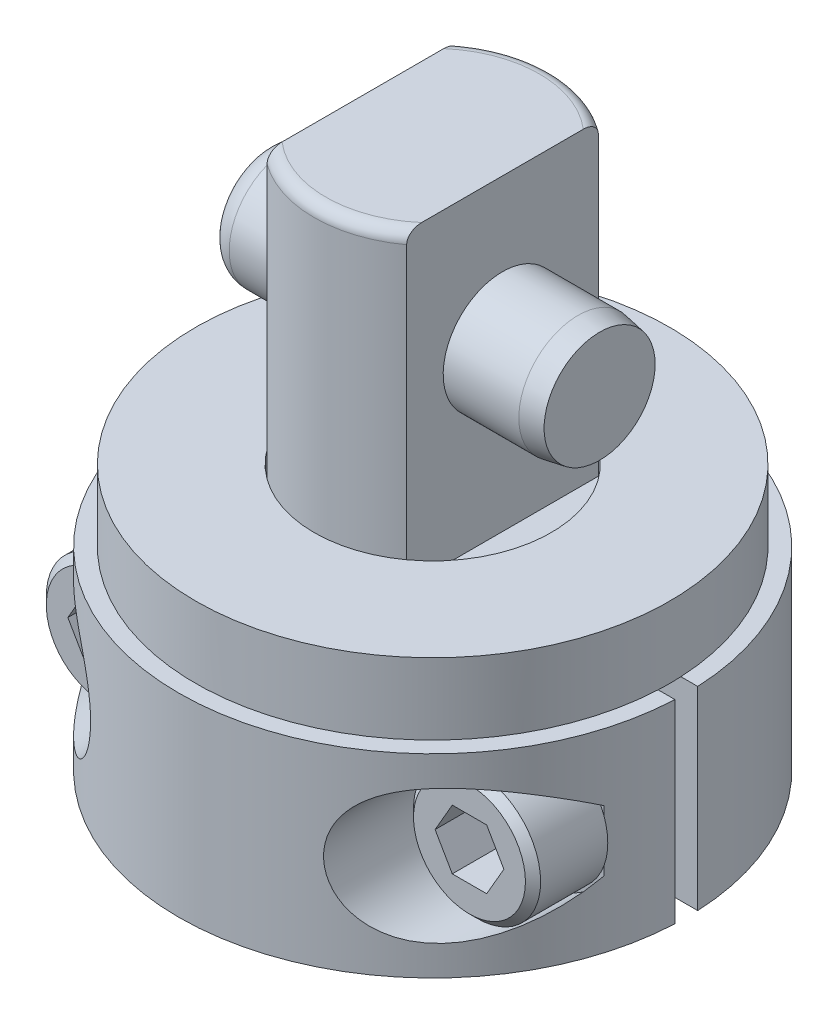
from build123d import *

# Parameters (mm, degrees)
FILLET1_R                  = 0.7874
SKETCH2_W                  = 3.2639
SKETCH2_H                  = 20.6248
CUT_EXTRUDE1_DEPTH         = 8.9375
CUT_EXTRUDE1_DEPTH_BACK    = 8.9375
SKETCH3_R                  = 5.0038
SKETCH3_R_2                = 3.9624
CUT_EXTRUDE2_DEPTH         = 2.54
CHAMFER1_SIZE              = 0.762
SKETCH4_R                  = 3.97129
EXTRUDE1_DEPTH             = 11.176
CHAMFER2_SIZE              = 0.254
CHAMFER2_SIZE2             = 1.440505582
FILLET2_R                  = 1.524
EXTRUDE2_DEPTH             = 6.5
EXTRUDE2_DEPTH_BACK        = 6.5
CUT_EXTRUDE3_START         = 4.064
SKETCH6_R                  = 4.4958
CUT_EXTRUDE3_DEPTH         = 13.174
SKETCH7_R                  = 4.2545
EXTRUDE3_DEPTH             = 5.0038
CHAMFER3_SIZE              = 0.508
CUT_EXTRUDE4_DEPTH         = 3.9878
EXTRUDE4_REACH             = 19
SKETCH10_R                 = 2.5019
EXTRUDE4_DIRECTION_2_REACH = 19
SKETCH11_R                 = 15.875
SKETCH11_R_2               = 7.9375
EXTRUDE5_DEPTH             = 4.774946


with BuildPart() as part:
    # Sketch1 → Revolve1 (revolve)
    with BuildSketch(Plane(origin=(0, 0, 0), x_dir=(0, 0, -1), z_dir=(1, 0, 0))):
        Polygon((0, 30.3276), (7.9375, 30.3276), (7.9375, 1.3462), (5.0038, 1.3462), (5.0038, -9.8298), (0, -9.8298), align=None)
    revolve(axis=Axis((0, -15.35938, 0), (0, 1, 0)))

    # Fillet1
    fillet1_edges = [part.edges().sort_by_distance(p)[0] for p in [
        (0, 30.3276, 7.9375),
    ]]
    fillet(fillet1_edges, radius=FILLET1_R)

    # Sketch2 → Cut-Extrude1 (cut, two sides)
    with BuildSketch(Plane.XY) as cut_extrude1_sk:
        with Locations((6.30555, 20.0152)):
            Rectangle(SKETCH2_W, SKETCH2_H)
        with Locations((-6.30555, 20.0152)):
            Rectangle(SKETCH2_W, SKETCH2_H)
    extrude(amount=CUT_EXTRUDE1_DEPTH, mode=Mode.SUBTRACT)
    extrude(cut_extrude1_sk.sketch, amount=-CUT_EXTRUDE1_DEPTH_BACK, mode=Mode.SUBTRACT)

    # Sketch3 → Cut-Extrude2 (cut)
    with BuildSketch(Plane.XZ.offset(-1.3462)):
        with Locations(Location((0, 0, 0), (0, 0, 270))):  # turned: the seam where the file's is
            Circle(SKETCH3_R)
        with Locations(Location((0, 0, 0), (0, 0, 270))):  # turned: the seam where the file's is
            Circle(SKETCH3_R_2, mode=Mode.SUBTRACT)
    extrude(amount=CUT_EXTRUDE2_DEPTH, mode=Mode.SUBTRACT)

    # Chamfer1
    chamfer1_edges = [part.edges().sort_by_distance(p)[0] for p in [
        (0, -9.8298, 5.0038),
    ]]
    chamfer(chamfer1_edges, length=CHAMFER1_SIZE)

    # Sketch4 → Extrude1 (add, symmetric)
    with BuildSketch(Plane(origin=(0, 0, 0), x_dir=(0, 0, -1), z_dir=(1, 0, 0))):
        with Locations(Location((0, 20.8026, 0), (0, 0, 90))):  # turned: the seam where the file's is
            Circle(SKETCH4_R)
    extrude(amount=EXTRUDE1_DEPTH, both=True)

    # Chamfer2
    chamfer2_edges = [part.edges().sort_by_distance(p)[0] for p in [
        (11.176, 16.83131, 0),
    ]]
    chamfer2_side = [part.faces().sort_by_distance(p)[0] for p in [
        (11.176, 20.8026, 0),
    ]]
    chamfer(chamfer2_edges, length=CHAMFER2_SIZE, length2=CHAMFER2_SIZE2, reference=chamfer2_side[0])

    # Fillet2
    fillet2_edges = [part.edges().sort_by_distance(p)[0] for p in [
        (-11.176, 16.83131, 0),
    ]]
    fillet(fillet2_edges, radius=FILLET2_R)

    # Sketch5 → Extrude2 (add, two sides)
    with BuildSketch(Plane(origin=(0, 0, 0), x_dir=(1, 0, 0), z_dir=(0, 1, 0))) as extrude2_sk:
        with BuildLine():
            Line((7.900839338, 0.762), (16.982913649, 0.762))
            ThreePointArc((16.982913649, 0.762), (0, 17), (-16.982913649, 0.762))
            Line((-16.982913649, 0.762), (-7.900839338, 0.762))
            ThreePointArc((-7.900839338, 0.762), (0, 7.9375), (7.900839338, 0.762))
        make_face()
        with BuildLine():
            Line((7.900839338, -0.762), (16.982913649, -0.762))
            ThreePointArc((16.982913649, -0.762), (0, -17), (-16.982913649, -0.762))
            Line((-16.982913649, -0.762), (-7.900839338, -0.762))
            ThreePointArc((-7.900839338, -0.762), (0, -7.9375), (7.900839338, -0.762))
        make_face()
    extrude(amount=EXTRUDE2_DEPTH)
    extrude(extrude2_sk.sketch, amount=-EXTRUDE2_DEPTH_BACK)

    # Sketch6 → Cut-Extrude3 (cut, through all)
    with BuildSketch(Plane.XY.offset(0.762).offset(CUT_EXTRUDE3_START)):
        with Locations((12.2936, 0)):
            Circle(SKETCH6_R)
        with Locations((-12.2936, 0)):
            Circle(SKETCH6_R)
    extrude(amount=CUT_EXTRUDE3_DEPTH, mode=Mode.SUBTRACT)

    # Sketch7 → Extrude3 (add)
    with BuildSketch(Plane.XY.offset(4.826)):
        with Locations(Location((12.2936, 0, 0), (0, 0, 340.36075817))):  # turned: the seam where the file's is
            Circle(SKETCH7_R)
        with Locations(Location((-12.2936, 0, 0), (0, 0, 160.36075817))):  # turned: the seam where the file's is
            Circle(SKETCH7_R)
    extrude(amount=EXTRUDE3_DEPTH)

    # Chamfer3
    chamfer3_edges = [part.edges().sort_by_distance(p)[0] for p in [
        (8.286594981, 1.429923433, 9.8298),
        (-8.286594981, -1.429923433, 9.8298),
    ]]
    chamfer(chamfer3_edges, length=CHAMFER3_SIZE)

    # Sketch8 → Cut-Extrude4 (cut)
    with BuildSketch(Plane.XY.offset(9.8298)):
        Polygon((13.444778702, 1.9939), (14.595957403, 0), (13.444778702, -1.9939), (11.142421298, -1.9939), (9.991242597, 0), (11.142421298, 1.9939), align=None)
        Polygon((-14.595957403, 0), (-13.444778702, -1.9939), (-11.142421298, -1.9939), (-9.991242597, 0), (-11.142421298, 1.9939), (-13.444778702, 1.9939), align=None)
    extrude(amount=-CUT_EXTRUDE4_DEPTH, mode=Mode.SUBTRACT)

    # Sketch10 → Extrude4 (add, up to next)
    with BuildSketch(Plane.XY, mode=Mode.PRIVATE) as extrude4_sk1:
        with Locations((12.2936, 0)):
            Circle(SKETCH10_R)
    extrude4_tool1 = extrude(extrude4_sk1.sketch, amount=EXTRUDE4_REACH, mode=Mode.PRIVATE) - part.part
    add(extrude4_tool1.solids().sort_by_distance((12.2936, 0, 0))[0])
    # Sketch10 → Extrude4 (add, up to next)
    with BuildSketch(Plane.XY, mode=Mode.PRIVATE) as extrude4_sk2:
        with Locations((-12.2936, 0)):
            Circle(SKETCH10_R)
    extrude4_tool2 = extrude(extrude4_sk2.sketch, amount=EXTRUDE4_REACH, mode=Mode.PRIVATE) - part.part
    add(extrude4_tool2.solids().sort_by_distance((-12.2936, 0, 0))[0])

    # Sketch10 → Extrude4 direction 2 (add, up to next)
    with BuildSketch(Plane.XY, mode=Mode.PRIVATE) as extrude4_direction_2_sk1:
        with Locations((12.2936, 0)):
            Circle(SKETCH10_R)
    extrude4_direction_2_tool1 = extrude(extrude4_direction_2_sk1.sketch, amount=-EXTRUDE4_DIRECTION_2_REACH, mode=Mode.PRIVATE) - part.part
    add(extrude4_direction_2_tool1.solids().sort_by_distance((12.2936, 0, 0))[0])
    # Sketch10 → Extrude4 direction 2 (add, up to next)
    with BuildSketch(Plane.XY, mode=Mode.PRIVATE) as extrude4_direction_2_sk2:
        with Locations((-12.2936, 0)):
            Circle(SKETCH10_R)
    extrude4_direction_2_tool2 = extrude(extrude4_direction_2_sk2.sketch, amount=-EXTRUDE4_DIRECTION_2_REACH, mode=Mode.PRIVATE) - part.part
    add(extrude4_direction_2_tool2.solids().sort_by_distance((-12.2936, 0, 0))[0])

    # Sketch11 → Extrude5 (add)
    with BuildSketch(Plane(origin=(0, 6.5, 0), x_dir=(-1, 0, 0), z_dir=(0, 1, 0))):
        with Locations(Location((0, 0, 0), (0, 0, 182.751254589))):  # turned: the seam where the file's is
            Circle(SKETCH11_R)
        Circle(SKETCH11_R_2, mode=Mode.SUBTRACT)
    extrude(amount=EXTRUDE5_DEPTH)


solid = part.part
